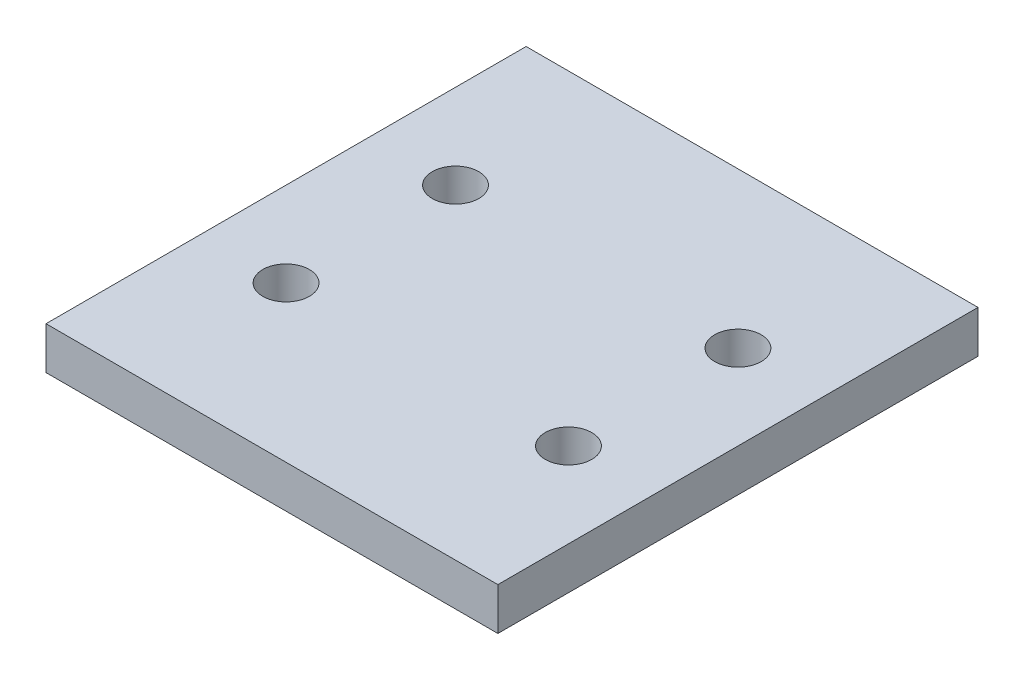
from build123d import *

# Parameters (mm, degrees)
SKETCH1_W           = 32
SKETCH1_H           = 34
SKETCH1_R           = 1.65
BOSS_EXTRUDE1_DEPTH = 3


with BuildPart() as part:
    # Sketch1 → Boss-Extrude1 (new body)
    with BuildSketch(Plane(origin=(0, 0, 0), x_dir=(1, 0, 0), z_dir=(0, 1, 0))):
        Rectangle(SKETCH1_W, SKETCH1_H)
        with Locations((-10, 6)):
            Circle(SKETCH1_R, mode=Mode.SUBTRACT)
        with Locations((10, 6)):
            Circle(SKETCH1_R, mode=Mode.SUBTRACT)
        with Locations((-10, -6)):
            Circle(SKETCH1_R, mode=Mode.SUBTRACT)
        with Locations((10, -6)):
            Circle(SKETCH1_R, mode=Mode.SUBTRACT)
    extrude(amount=BOSS_EXTRUDE1_DEPTH)


solid = part.part
